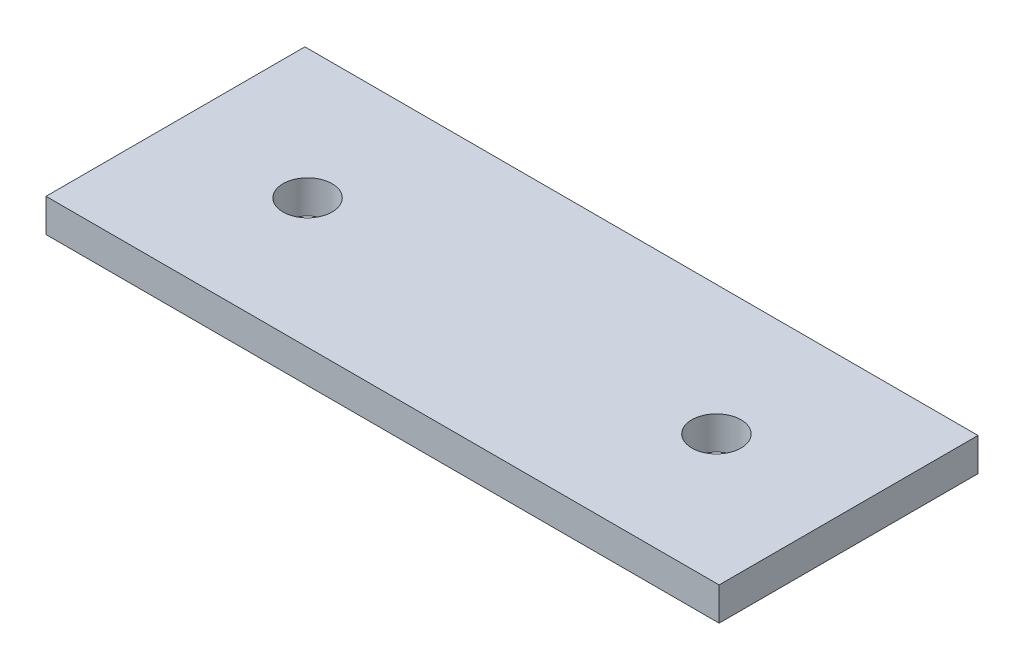
from build123d import *

# Parameters (mm, degrees)
SKETCH1_W                 = 30.95625
SKETCH1_H                 = 11.90625
BOSS_EXTRUDE1_DEPTH       = 1.524
F_4_40_TAPPED_HOLE1_D     = 2.2606
F_4_40_TAPPED_HOLE1_DEPTH = 8.89
F_4_40_TAPPED_HOLE1_TIP   = 0.679152758


with BuildPart() as part:
    # Sketch1 → Boss-Extrude1 (new body)
    with BuildSketch(Plane(origin=(0, 0, 0), x_dir=(1, 0, 0), z_dir=(0, 1, 0))):
        Rectangle(SKETCH1_W, SKETCH1_H)
    extrude(amount=BOSS_EXTRUDE1_DEPTH)

    # #4-40 Tapped Hole1
    with Locations(Plane(origin=(0, 1.524, 0), x_dir=(-1, 0, 0), z_dir=(0, 1, 0))):
        with Locations((9.402022244, 0), (-9.402022244, 0)):
            Hole(F_4_40_TAPPED_HOLE1_D / 2, depth=F_4_40_TAPPED_HOLE1_DEPTH)
            with Locations((0, 0, -(F_4_40_TAPPED_HOLE1_DEPTH + F_4_40_TAPPED_HOLE1_TIP / 2))):  # 118° drill point
                Cone(0, F_4_40_TAPPED_HOLE1_D / 2, F_4_40_TAPPED_HOLE1_TIP, mode=Mode.SUBTRACT)


solid = part.part
